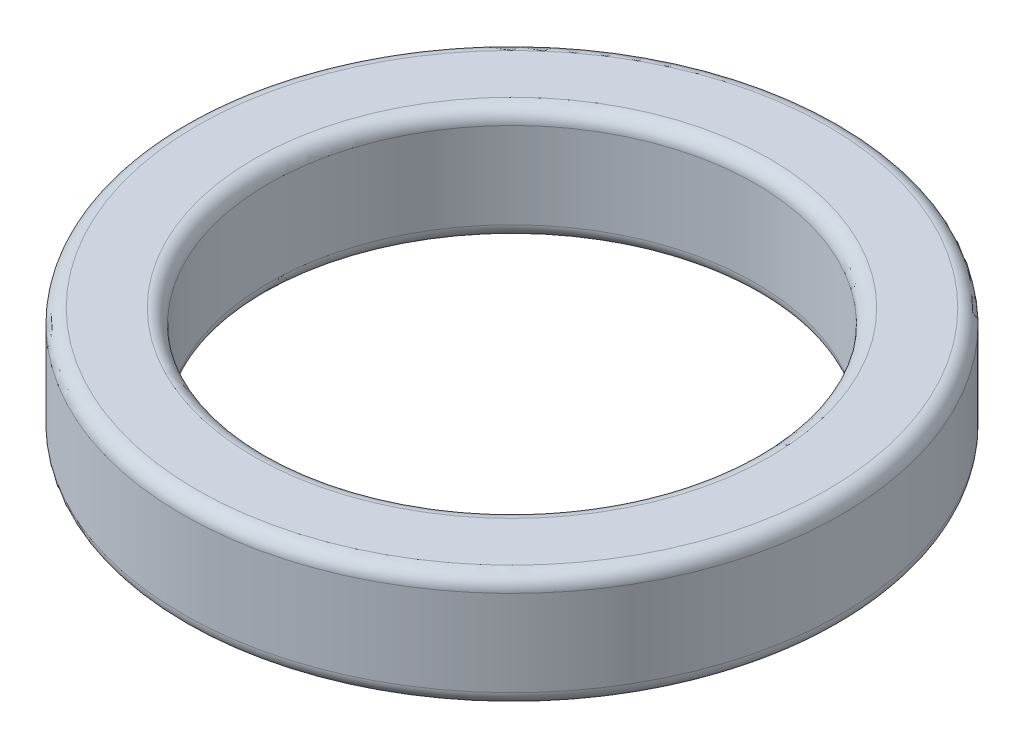
from build123d import *

# Parameters (mm, degrees)
SKIZZE1_R                       = 11.5
SKIZZE1_R_2                     = 8.5
AUFSATZ_LINEAR_AUSTRAGEN1_DEPTH = 4
VERRUNDUNG1_R                   = 0.5


with BuildPart() as part:
    # Skizze1 → Aufsatz-Linear austragen1 (new body)
    with BuildSketch(Plane(origin=(0, 0, 0), x_dir=(1, 0, 0), z_dir=(0, 1, 0))):
        Circle(SKIZZE1_R)
        Circle(SKIZZE1_R_2, mode=Mode.SUBTRACT)
    extrude(amount=AUFSATZ_LINEAR_AUSTRAGEN1_DEPTH)

    # Verrundung1
    verrundung1_edges = [part.edges().sort_by_distance(p)[0] for p in [
        (-11.5, 0, 0),
        (-11.5, 4, 0),
        (-8.5, 0, 0),
        (-8.5, 4, 0),
    ]]
    fillet(verrundung1_edges, radius=VERRUNDUNG1_R)


solid = part.part
